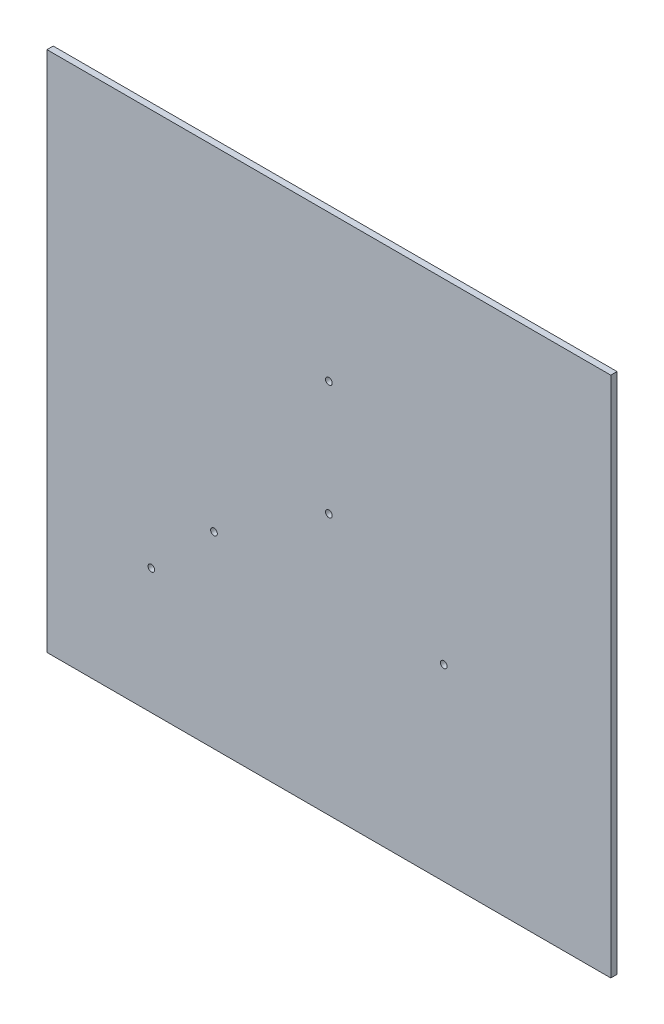
from build123d import *

# Parameters (mm, degrees)
SKETCH_1_W      = 270
SKETCH_1_H      = 250
SKETCH_1_R      = 1.6
EXTRUDE_1_DEPTH = 3


with BuildPart() as part:
    # ｽｹｯﾁ1 → ﾎﾞｽ - 押し出し1 (new body)
    with BuildSketch(Plane.XY):
        Rectangle(SKETCH_1_W, SKETCH_1_H)
        with Locations((-85, -65)):
            Circle(SKETCH_1_R, mode=Mode.SUBTRACT)
        with Locations((0, 55)):
            Circle(SKETCH_1_R, mode=Mode.SUBTRACT)
        with Locations((-55, -35)):
            Circle(SKETCH_1_R, mode=Mode.SUBTRACT)
        with Locations((55, -35)):
            Circle(SKETCH_1_R, mode=Mode.SUBTRACT)
        Circle(SKETCH_1_R, mode=Mode.SUBTRACT)
    extrude(amount=EXTRUDE_1_DEPTH)


solid = part.part
